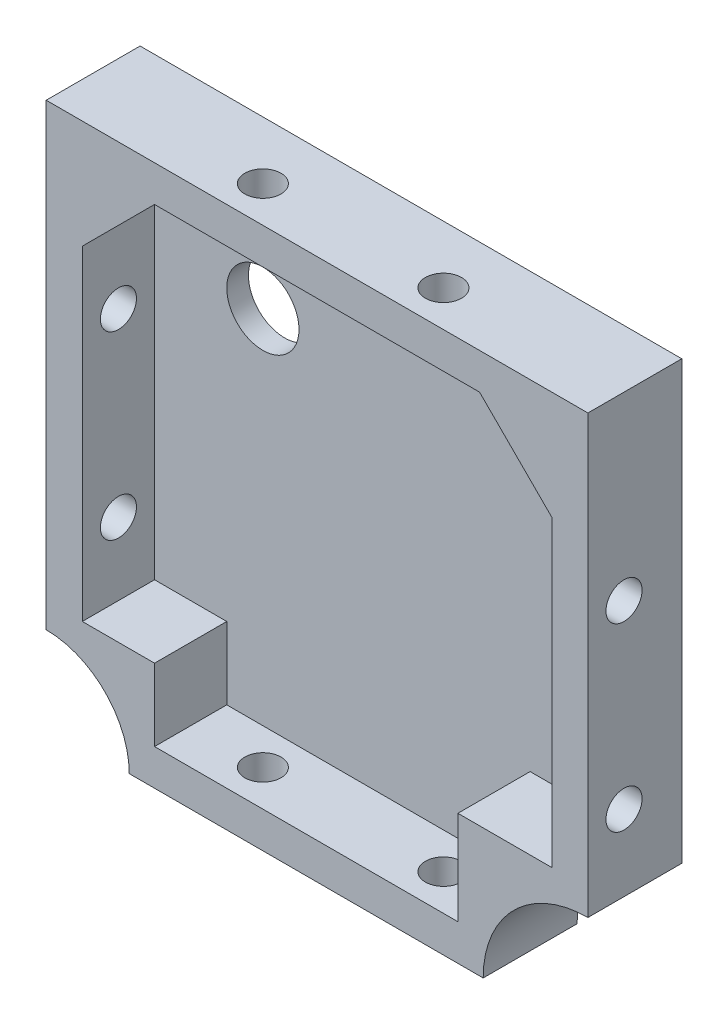
from build123d import *

# Parameters (mm, degrees)
BOSS_EXTRU_1_DEPTH        = 13
COQUE1_T                  = -5
COQUE1_THICKNESS_2_FACE_W = 65
COQUE1_THICKNESS_2_FACE_H = 65
COQUE1_THICKNESS_2_DEPTH  = 2
ENL_V_MAT_EXTRU_1_REACH   = 88.587
ESQUISSE2_R               = 2.5
ENL_V_MAT_EXTRU_2_REACH   = 95.396
ESQUISSE3_R               = 2.5
ESQUISSE4_W               = 18
ESQUISSE4_H               = 18
ESQUISSE4_W_2             = 15
ESQUISSE4_H_2             = 15
BOSS_EXTRU_2_DEPTH        = 10
ESQUISSE5_R               = 11.5
ESQUISSE5_R_2             = 14.5
ENL_V_MAT_EXTRU_3_DEPTH   = 13
ESQUISSE6_R               = 5
ENL_V_MAT_EXTRU_4_DEPTH   = 3


with BuildPart() as part:
    # Esquisse1 → Boss.-Extru.1 (new body)
    with BuildSketch(Plane.XY):
        Polygon((44.118436308, 33.728448276), (54.118436308, 33.728448276), (54.118436308, 23.728448276), (54.118436308, -41.271551724), (-20.881563692, -41.271551724), (-20.881563692, 33.728448276), align=None)
    extrude(amount=BOSS_EXTRU_1_DEPTH)

    # Coque1
    coque1_openings = [part.faces().sort_by_distance(p)[0] for p in [
        (16.618436308, -3.771551724, 13),
    ]]
    offset(amount=COQUE1_T, openings=coque1_openings, kind=Kind.INTERSECTION)

    # Coque1 thickness 2 face (on inner face of the shell) → Coque1 thickness 2 (cut)
    with BuildSketch(Plane(origin=(16.618436308, -3.771551724, 5), x_dir=(-1, 0, 0), z_dir=(0, 0, -1))):
        Rectangle(COQUE1_THICKNESS_2_FACE_W, COQUE1_THICKNESS_2_FACE_H)
    extrude(amount=COQUE1_THICKNESS_2_DEPTH, mode=Mode.SUBTRACT)

    # Enlèv. mat.-Extru.1: up to this face of the body (flat: up to its plane)
    enl_v_mat_extru_1_end = Plane(part.part.faces().sort_by_distance((54.118436308, -3.771551724, 6.5))[0])
    # Esquisse2 → Enlèv. mat.-Extru.1 (cut, up to the picked face)
    with BuildSketch(Plane.ZY.offset(20.881563692), mode=Mode.PRIVATE) as enl_v_mat_extru_1_sk1:
        with Locations(Location((8, -16.271551724, 0), (0, 0, 270))):
            Circle(ESQUISSE2_R)
    enl_v_mat_extru_1_tool1 = split(extrude(enl_v_mat_extru_1_sk1.sketch, amount=-ENL_V_MAT_EXTRU_1_REACH, mode=Mode.PRIVATE), bisect_by=enl_v_mat_extru_1_end, keep=Keep.BOTH, mode=Mode.PRIVATE)
    # Esquisse2 → Enlèv. mat.-Extru.1 (cut, up to the picked face)
    with BuildSketch(Plane.ZY.offset(20.881563692), mode=Mode.PRIVATE) as enl_v_mat_extru_1_sk2:
        with Locations(Location((8, 8.728448276, 0), (0, 0, 270))):
            Circle(ESQUISSE2_R)
    enl_v_mat_extru_1_tool2 = split(extrude(enl_v_mat_extru_1_sk2.sketch, amount=-ENL_V_MAT_EXTRU_1_REACH, mode=Mode.PRIVATE), bisect_by=enl_v_mat_extru_1_end, keep=Keep.BOTH, mode=Mode.PRIVATE)
    add(enl_v_mat_extru_1_tool1.solids().sort_by(Axis((-20.881564, -16.271552, 8), (1, 0, 0)))[0], mode=Mode.SUBTRACT)
    add(enl_v_mat_extru_1_tool2.solids().sort_by(Axis((-20.881564, 8.728448, 8), (1, 0, 0)))[0], mode=Mode.SUBTRACT)

    # Enlèv. mat.-Extru.2: up to this face of the body (flat: up to its plane)
    enl_v_mat_extru_2_end = Plane(part.part.faces().sort_by_distance((16.618436308, 33.728448276, 6.5))[0])
    # Esquisse3 → Enlèv. mat.-Extru.2 (cut, up to the picked face)
    with BuildSketch(Plane.XZ.offset(41.271551724), mode=Mode.PRIVATE) as enl_v_mat_extru_2_sk1:
        with Locations(Location((4.118436308, 8, 0), (0, 0, 270))):
            Circle(ESQUISSE3_R)
    enl_v_mat_extru_2_tool1 = split(extrude(enl_v_mat_extru_2_sk1.sketch, amount=-ENL_V_MAT_EXTRU_2_REACH, mode=Mode.PRIVATE), bisect_by=enl_v_mat_extru_2_end, keep=Keep.BOTH, mode=Mode.PRIVATE)
    # Esquisse3 → Enlèv. mat.-Extru.2 (cut, up to the picked face)
    with BuildSketch(Plane.XZ.offset(41.271551724), mode=Mode.PRIVATE) as enl_v_mat_extru_2_sk2:
        with Locations(Location((29.118436308, 8, 0), (0, 0, 270))):
            Circle(ESQUISSE3_R)
    enl_v_mat_extru_2_tool2 = split(extrude(enl_v_mat_extru_2_sk2.sketch, amount=-ENL_V_MAT_EXTRU_2_REACH, mode=Mode.PRIVATE), bisect_by=enl_v_mat_extru_2_end, keep=Keep.BOTH, mode=Mode.PRIVATE)
    add(enl_v_mat_extru_2_tool1.solids().sort_by(Axis((4.118436, -41.271552, 8), (0, 1, 0)))[0], mode=Mode.SUBTRACT)
    add(enl_v_mat_extru_2_tool2.solids().sort_by(Axis((29.118436, -41.271552, 8), (0, 1, 0)))[0], mode=Mode.SUBTRACT)

    # Esquisse4 → Boss.-Extru.2 (add)
    with BuildSketch(Plane.XY.offset(3)):
        Polygon((-5.881563692, 28.728448276), (-15.881563692, 18.728448276), (-15.881563692, 28.728448276), align=None)
        Polygon((49.118436308, 28.728448276), (49.118436308, 18.728448276), (39.118436308, 28.728448276), align=None)
        with Locations((45.118436308, -32.271551724)):
            Rectangle(ESQUISSE4_W, ESQUISSE4_H)
        with Locations((-13.381563692, -33.771551724)):
            Rectangle(ESQUISSE4_W_2, ESQUISSE4_H_2)
    extrude(amount=BOSS_EXTRU_2_DEPTH)

    # Esquisse5 → Enlèv. mat.-Extru.3 (cut)
    with BuildSketch(Plane.XY.offset(13)):
        with Locations((-20.881563692, -41.271551724)):
            Circle(ESQUISSE5_R)
        with Locations((54.118436308, -41.271551724)):
            Circle(ESQUISSE5_R_2)
    extrude(amount=-ENL_V_MAT_EXTRU_3_DEPTH, mode=Mode.SUBTRACT)

    # Esquisse6 → Enlèv. mat.-Extru.4 (cut)
    with BuildSketch(Plane.XY.offset(3)):
        with Locations((-0.881563692, 13.728448276)):
            Circle(ESQUISSE6_R)
    extrude(amount=-ENL_V_MAT_EXTRU_4_DEPTH, mode=Mode.SUBTRACT)


solid = part.part
